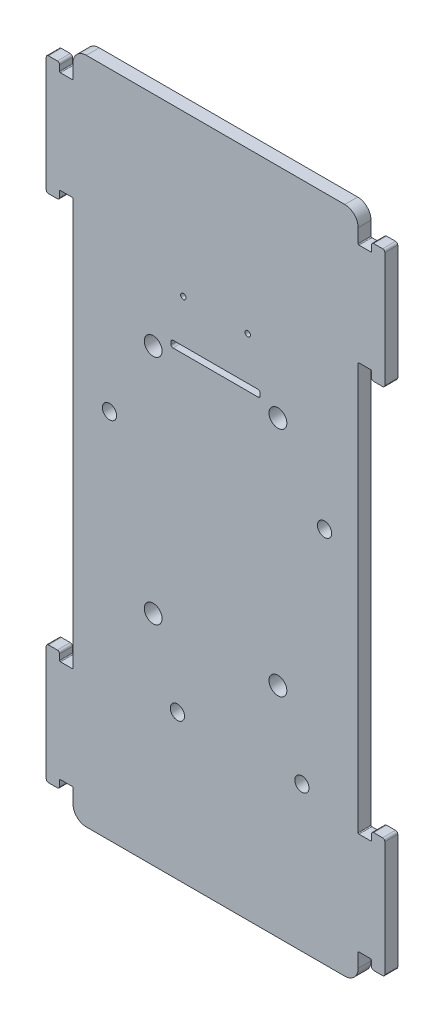
from build123d import *

# Parameters (mm, degrees)
EXTRUDE_1_DEPTH     = 1.45
CUT_EXTRUDE_1_REACH = 4.9
SKETCH_2_R          = 1.6
SKETCH_3_R          = 2
CUT_EXTRUDE_2_DEPTH = 10
SKETCH_4_R          = 0.6
CUT_EXTRUDE_3_DEPTH = 10


with BuildPart() as part:
    # 草图1 → 凸台-拉伸1 (new body, symmetric)
    with BuildSketch(Plane.XY):
        with BuildLine():
            Line((32.2, 68.7), (34.8, 68.7))
            ThreePointArc((34.8, 68.7), (34.941421356, 68.758578644), (35, 68.9))
            Line((35, 68.9), (35, 70.15))
            ThreePointArc((35, 70.15), (35.146446609, 70.503553391), (35.5, 70.65))
            Line((35.5, 70.65), (37.5, 70.65))
            ThreePointArc((37.5, 70.65), (37.853553391, 70.503553391), (38, 70.15))
            Line((38, 70.15), (38, 44.35))
            ThreePointArc((38, 44.35), (37.853553391, 43.996446609), (37.5, 43.85))
            Line((37.5, 43.85), (35.5, 43.85))
            ThreePointArc((35.5, 43.85), (35.146446609, 43.996446609), (35, 44.35))
            Line((35, 44.35), (35, 45.6))
            ThreePointArc((35, 45.6), (34.941421356, 45.741421356), (34.8, 45.8))
            Line((34.8, 45.8), (32.2, 45.8))
            ThreePointArc((32.2, 45.8), (32.058578644, 45.741421356), (32, 45.6))
            Line((32, 45.6), (32, -45.6))
            ThreePointArc((32, -45.6), (32.058578644, -45.741421356), (32.2, -45.8))
            Line((32.2, -45.8), (34.8, -45.8))
            ThreePointArc((34.8, -45.8), (34.941421356, -45.741421356), (35, -45.6))
            Line((35, -45.6), (35, -44.35))
            ThreePointArc((35, -44.35), (35.146446609, -43.996446609), (35.5, -43.85))
            Line((35.5, -43.85), (37.5, -43.85))
            ThreePointArc((37.5, -43.85), (37.853553391, -43.996446609), (38, -44.35))
            Line((38, -44.35), (38, -70.15))
            ThreePointArc((38, -70.15), (37.853553391, -70.503553391), (37.5, -70.65))
            Line((37.5, -70.65), (35.5, -70.65))
            ThreePointArc((35.5, -70.65), (35.146446609, -70.503553391), (35, -70.15))
            Line((35, -70.15), (35, -68.9))
            ThreePointArc((35, -68.9), (34.941421356, -68.758578644), (34.8, -68.7))
            Line((34.8, -68.7), (32.2, -68.7))
            ThreePointArc((32.2, -68.7), (32.058578644, -68.758578644), (32, -68.9))
            Line((32, -68.9), (32, -72))
            ThreePointArc((32, -72), (31.121320344, -74.121320344), (29, -75))
            Line((29, -75), (-29, -75))
            ThreePointArc((-29, -75), (-31.121320344, -74.121320344), (-32, -72))
            Line((-32, -72), (-32, -68.9))
            ThreePointArc((-32, -68.9), (-32.058578644, -68.758578644), (-32.2, -68.7))
            Line((-32.2, -68.7), (-34.8, -68.7))
            ThreePointArc((-34.8, -68.7), (-34.941421356, -68.758578644), (-35, -68.9))
            Line((-35, -68.9), (-35, -70.15))
            ThreePointArc((-35, -70.15), (-35.146446609, -70.503553391), (-35.5, -70.65))
            Line((-35.5, -70.65), (-37.5, -70.65))
            ThreePointArc((-37.5, -70.65), (-37.853553391, -70.503553391), (-38, -70.15))
            Line((-38, -70.15), (-38, -44.35))
            ThreePointArc((-38, -44.35), (-37.853553391, -43.996446609), (-37.5, -43.85))
            Line((-37.5, -43.85), (-35.5, -43.85))
            ThreePointArc((-35.5, -43.85), (-35.146446609, -43.996446609), (-35, -44.35))
            Line((-35, -44.35), (-35, -45.6))
            ThreePointArc((-35, -45.6), (-34.941421356, -45.741421356), (-34.8, -45.8))
            Line((-34.8, -45.8), (-32.2, -45.8))
            ThreePointArc((-32.2, -45.8), (-32.058578644, -45.741421356), (-32, -45.6))
            Line((-32, -45.6), (-32, 45.6))
            ThreePointArc((-32, 45.6), (-32.058578644, 45.741421356), (-32.2, 45.8))
            Line((-32.2, 45.8), (-34.8, 45.8))
            ThreePointArc((-34.8, 45.8), (-34.941421356, 45.741421356), (-35, 45.6))
            Line((-35, 45.6), (-35, 44.35))
            ThreePointArc((-35, 44.35), (-35.146446609, 43.996446609), (-35.5, 43.85))
            Line((-35.5, 43.85), (-37.5, 43.85))
            ThreePointArc((-37.5, 43.85), (-37.853553391, 43.996446609), (-38, 44.35))
            Line((-38, 44.35), (-38, 70.15))
            ThreePointArc((-38, 70.15), (-37.853553391, 70.503553391), (-37.5, 70.65))
            Line((-37.5, 70.65), (-35.5, 70.65))
            ThreePointArc((-35.5, 70.65), (-35.146446609, 70.503553391), (-35, 70.15))
            Line((-35, 70.15), (-35, 68.9))
            ThreePointArc((-35, 68.9), (-34.941421356, 68.758578644), (-34.8, 68.7))
            Line((-34.8, 68.7), (-32.2, 68.7))
            ThreePointArc((-32.2, 68.7), (-32.058578644, 68.758578644), (-32, 68.9))
            Line((-32, 68.9), (-32, 72))
            ThreePointArc((-32, 72), (-31.121320344, 74.121320344), (-29, 75))
            Line((-29, 75), (29, 75))
            ThreePointArc((29, 75), (31.121320344, 74.121320344), (32, 72))
            Line((32, 72), (32, 68.9))
            ThreePointArc((32, 68.9), (32.058578644, 68.758578644), (32.2, 68.7))
        make_face()
    extrude(amount=EXTRUDE_1_DEPTH, both=True)

    # 草图2 → 切除-拉伸1 (cut, up to next)
    with BuildSketch(Plane(origin=(0, 0, -1.45), x_dir=(-1, 0, 0), z_dir=(0, 0, -1)), mode=Mode.PRIVATE) as cut_extrude_1_sk1:
        with Locations((23.8, 8.34)):
            Circle(SKETCH_2_R)
    cut_extrude_1_tool1 = extrude(cut_extrude_1_sk1.sketch, amount=-CUT_EXTRUDE_1_REACH, mode=Mode.PRIVATE) & part.part
    add(cut_extrude_1_tool1.solids().sort_by_distance((-23.8, 8.34, -1.45))[0], mode=Mode.SUBTRACT)
    # 草图2 → 切除-拉伸1 (cut, up to next)
    with BuildSketch(Plane(origin=(0, 0, -1.45), x_dir=(-1, 0, 0), z_dir=(0, 0, -1)), mode=Mode.PRIVATE) as cut_extrude_1_sk2:
        with Locations((8.56, -42.46)):
            Circle(SKETCH_2_R)
    cut_extrude_1_tool2 = extrude(cut_extrude_1_sk2.sketch, amount=-CUT_EXTRUDE_1_REACH, mode=Mode.PRIVATE) & part.part
    add(cut_extrude_1_tool2.solids().sort_by_distance((-8.56, -42.46, -1.45))[0], mode=Mode.SUBTRACT)
    # 草图2 → 切除-拉伸1 (cut, up to next)
    with BuildSketch(Plane(origin=(0, 0, -1.45), x_dir=(-1, 0, 0), z_dir=(0, 0, -1)), mode=Mode.PRIVATE) as cut_extrude_1_sk3:
        with Locations((-19.38, -42.46)):
            Circle(SKETCH_2_R)
    cut_extrude_1_tool3 = extrude(cut_extrude_1_sk3.sketch, amount=-CUT_EXTRUDE_1_REACH, mode=Mode.PRIVATE) & part.part
    add(cut_extrude_1_tool3.solids().sort_by_distance((19.38, -42.46, -1.45))[0], mode=Mode.SUBTRACT)
    # 草图2 → 切除-拉伸1 (cut, up to next)
    with BuildSketch(Plane(origin=(0, 0, -1.45), x_dir=(-1, 0, 0), z_dir=(0, 0, -1)), mode=Mode.PRIVATE) as cut_extrude_1_sk4:
        with Locations((-24.46, 9.61)):
            Circle(SKETCH_2_R)
    cut_extrude_1_tool4 = extrude(cut_extrude_1_sk4.sketch, amount=-CUT_EXTRUDE_1_REACH, mode=Mode.PRIVATE) & part.part
    add(cut_extrude_1_tool4.solids().sort_by_distance((24.46, 9.61, -1.45))[0], mode=Mode.SUBTRACT)

    # 草图3 → 切除-拉伸2 (cut)
    with BuildSketch(Plane.XY.offset(1.45)):
        with Locations((14, 26)):
            Circle(SKETCH_3_R)
        with Locations((14, -26)):
            Circle(SKETCH_3_R)
        with Locations((-14, 26)):
            Circle(SKETCH_3_R)
        with Locations((-14, -26)):
            Circle(SKETCH_3_R)
    extrude(amount=-CUT_EXTRUDE_2_DEPTH, mode=Mode.SUBTRACT)

    # 草图4 → 切除-拉伸3 (cut)
    with BuildSketch(Plane.XY.offset(1.45)):
        with Locations((-7.23, 39)):
            Circle(SKETCH_4_R)
        with Locations((7.23, 39)):
            Circle(SKETCH_4_R)
        with BuildLine():
            Line((-9.55, 29.34), (9.55, 29.34))
            ThreePointArc((9.55, 29.34), (9.868198052, 29.208198052), (10, 28.89))
            Line((10, 28.89), (10, 28.29))
            ThreePointArc((10, 28.29), (9.868198052, 27.971801948), (9.55, 27.84))
            Line((9.55, 27.84), (-9.55, 27.84))
            ThreePointArc((-9.55, 27.84), (-9.868198052, 27.971801948), (-10, 28.29))
            Line((-10, 28.29), (-10, 28.89))
            ThreePointArc((-10, 28.89), (-9.868198052, 29.208198052), (-9.55, 29.34))
        make_face()
    extrude(amount=-CUT_EXTRUDE_3_DEPTH, mode=Mode.SUBTRACT)


solid = part.part
